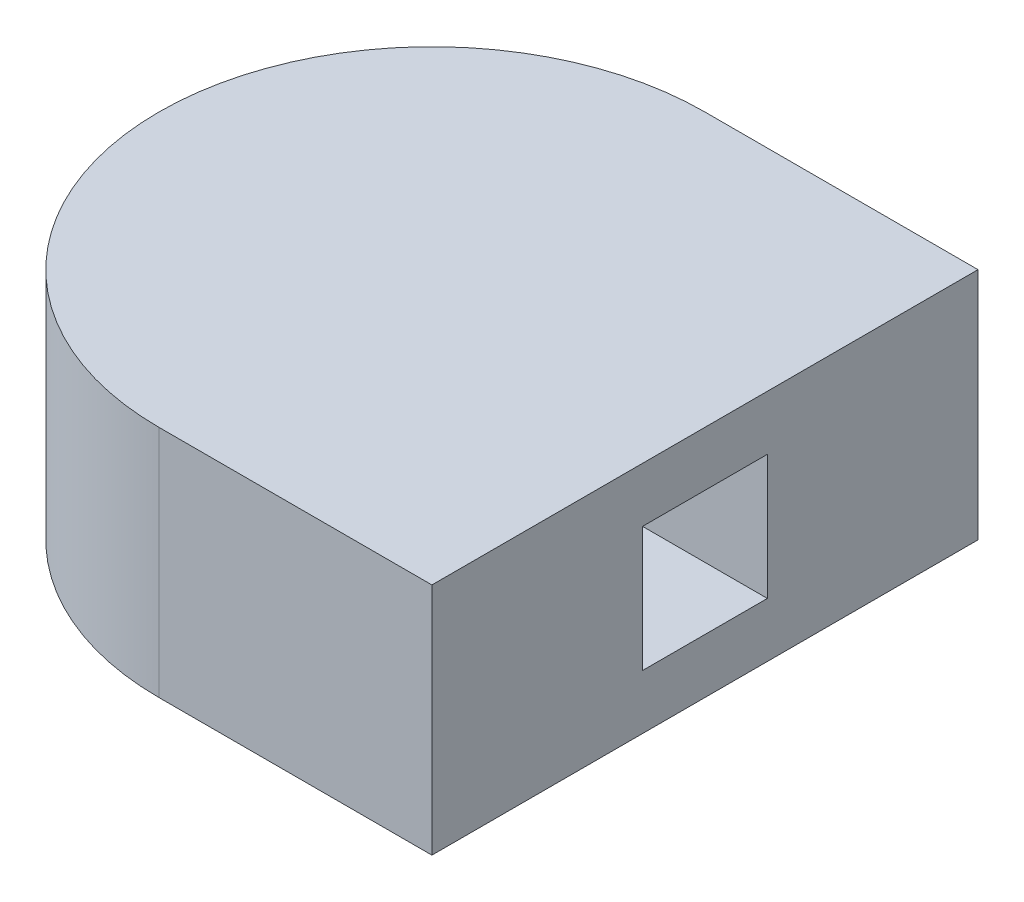
from build123d import *

# Parameters (mm, degrees)
SKETCH1_W                       = 22.225
SKETCH1_H                       = 44.45
MAIN_BODY_EXTRUDE_DEPTH         = 19.05
SKETCH2_W                       = 10.16
SKETCH2_H                       = 10.16
UPPER_FOOT_CONNECTION_CUT_DEPTH = 15.24


with BuildPart() as part:
    # Sketch1 → Main body extrude (new body)
    with BuildSketch(Plane(origin=(0, 0, 0), x_dir=(1, 0, 0), z_dir=(0, 1, 0))):
        with BuildLine():
            Line((22.225, 44.45), (22.225, 0))
            ThreePointArc((22.225, 0), (0, 22.225), (22.225, 44.45))
        make_face()
        with Locations((33.3375, 22.225)):
            Rectangle(SKETCH1_W, SKETCH1_H)
    extrude(amount=MAIN_BODY_EXTRUDE_DEPTH)

    # Sketch2 → Upper foot connection cut (cut)
    with BuildSketch(Plane(origin=(44.45, 0, 0), x_dir=(0, 0, -1), z_dir=(1, 0, 0))):
        with Locations((22.225, 9.525)):
            Rectangle(SKETCH2_W, SKETCH2_H)
    extrude(amount=-UPPER_FOOT_CONNECTION_CUT_DEPTH, mode=Mode.SUBTRACT)


solid = part.part
